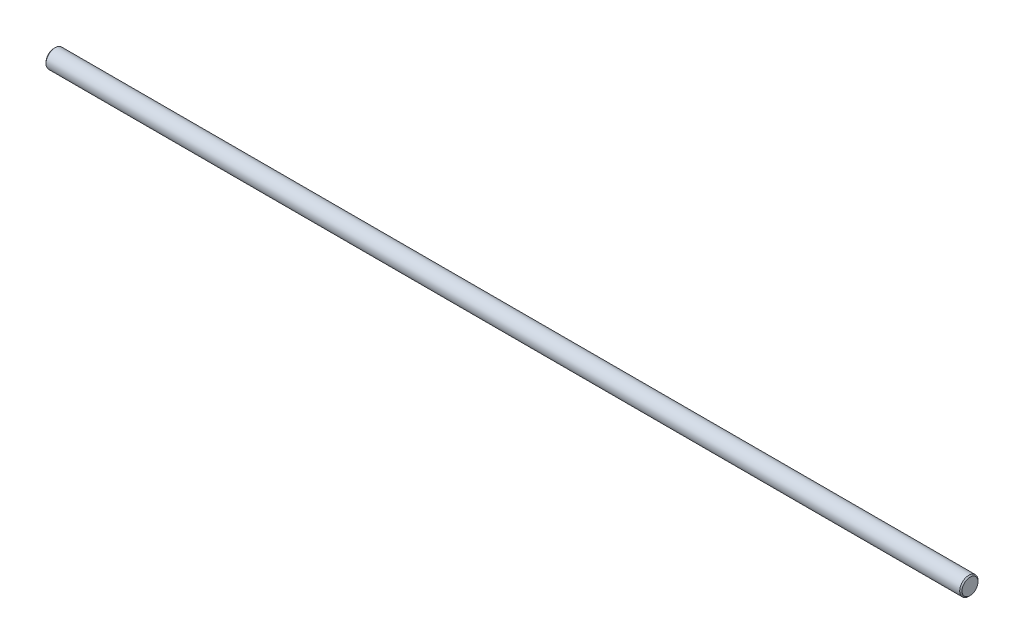
from build123d import *


with BuildPart() as part:
    # Sketch1 → Revolve1 (revolve)
    with BuildSketch(Plane.XY):
        Polygon((0, 0), (0, 3.5), (0.5, 4), (399.5, 4), (400, 3.5), (400, 0), align=None)
    revolve(axis=Axis((400, 0, 0), (-1, 0, 0)))


solid = part.part
